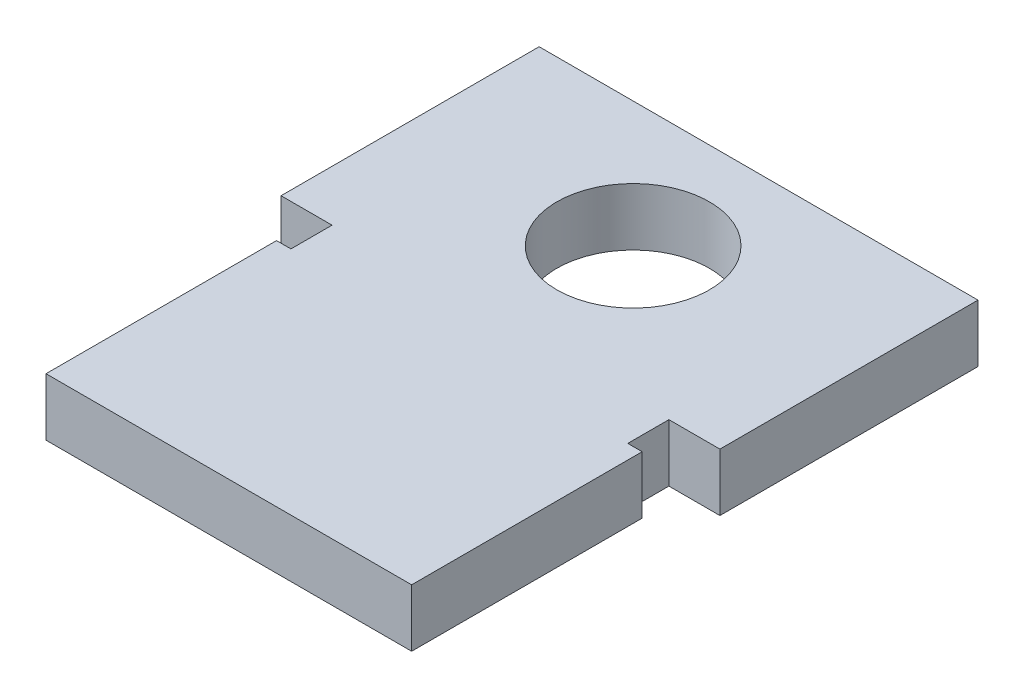
from build123d import *

# Parameters (mm, degrees)
SKETCH1_W           = 10.67
SKETCH1_H           = 12.88
SKETCH1_R           = 1.855
BOSS_EXTRUDE1_DEPTH = 1.4
SKETCH2_W           = 0.89
SKETCH2_H           = 6.605
CUT_EXTRUDE1_DEPTH  = 2.4
SKETCH3_W           = 0.35
SKETCH3_H           = 1
CUT_EXTRUDE2_DEPTH  = 2.4


with BuildPart() as part:
    # Sketch1 → Boss-Extrude1 (new body)
    with BuildSketch(Plane(origin=(0, 0, 0), x_dir=(1, 0, 0), z_dir=(0, 1, 0))):
        with Locations((0, -3.39)):
            Rectangle(SKETCH1_W, SKETCH1_H)
        Circle(SKETCH1_R, mode=Mode.SUBTRACT)
    extrude(amount=BOSS_EXTRUDE1_DEPTH)

    # Sketch2 → Cut-Extrude1 (cut, through all)
    with BuildSketch(Plane(origin=(0, 1.4, 0), x_dir=(1, 0, 0), z_dir=(0, 1, 0))):
        with Locations((-4.89, -6.5275)):
            Rectangle(SKETCH2_W, SKETCH2_H)
    cut_extrude1 = extrude(amount=-CUT_EXTRUDE1_DEPTH, mode=Mode.SUBTRACT)

    # Mirror1: Cut-Extrude1 across plane
    add(cut_extrude1.mirror(Plane(origin=(0, 0, 0), x_dir=(0, 0, 1), z_dir=(1, 0, 0))), mode=Mode.SUBTRACT)

    # Sketch3 → Cut-Extrude2 (cut, through all)
    with BuildSketch(Plane(origin=(0, 1.4, 0), x_dir=(1, 0, 0), z_dir=(0, 1, 0))):
        with Locations((-4.27, -3.725)):
            Rectangle(SKETCH3_W, SKETCH3_H)
    cut_extrude2 = extrude(amount=-CUT_EXTRUDE2_DEPTH, mode=Mode.SUBTRACT)

    # Mirror2: Cut-Extrude2 across plane
    add(cut_extrude2.mirror(Plane(origin=(0, 0, 0), x_dir=(0, 0, 1), z_dir=(1, 0, 0))), mode=Mode.SUBTRACT)


solid = part.part
